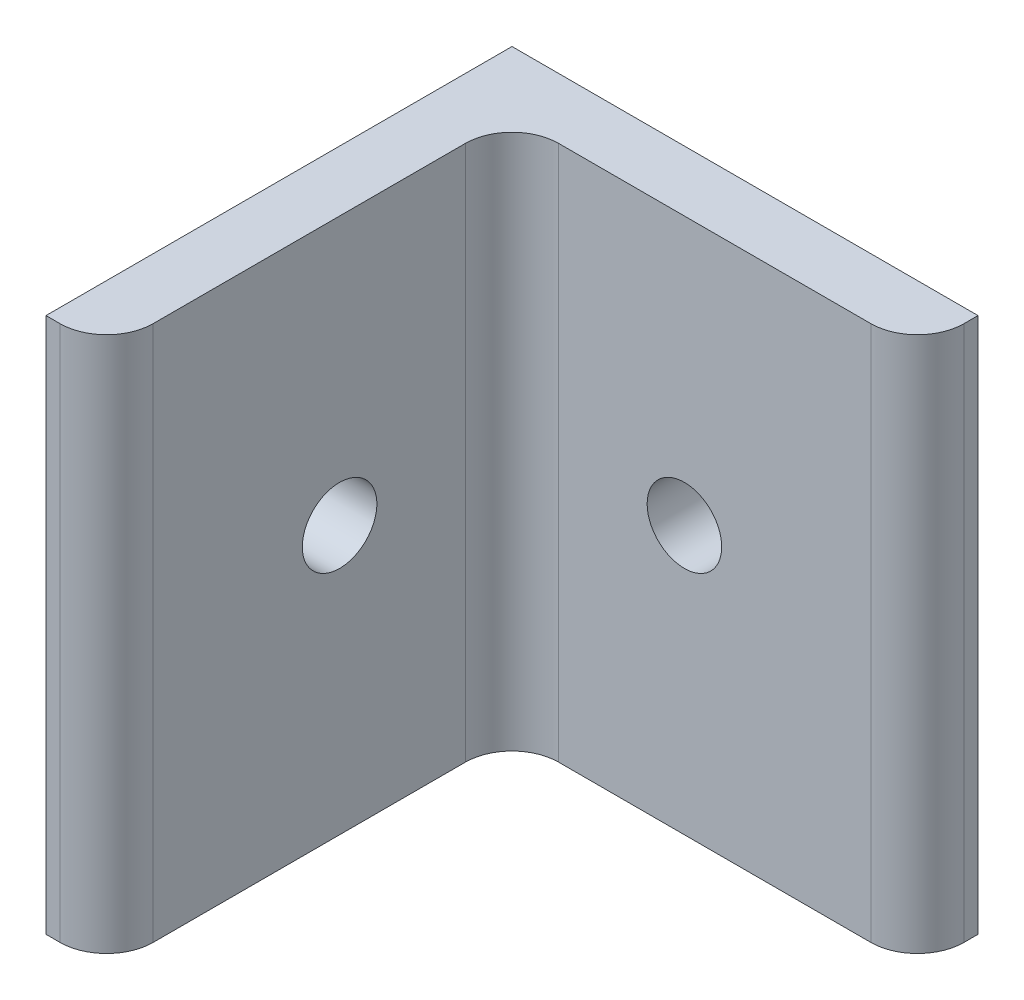
from build123d import *

# Parameters (mm, degrees)
BOSS_EXTRUDE1_DEPTH = 29.21
FILLET1_R           = 2.54
SKETCH2_R           = 2.032
CUT_EXTRUDE1_DEPTH  = 26.4
SKETCH3_R           = 2.032
CUT_EXTRUDE2_DEPTH  = 26.4


with BuildPart() as part:
    # Sketch1 → Boss-Extrude1 (new body)
    with BuildSketch(Plane(origin=(0, 0, 0), x_dir=(1, 0, 0), z_dir=(0, 1, 0))):
        Polygon((0, 0), (0, -25.4), (3.302, -25.4), (3.302, -3.302), (25.4, -3.302), (25.4, 0), align=None)
    extrude(amount=BOSS_EXTRUDE1_DEPTH)

    # Fillet1
    fillet1_edges = [part.edges().sort_by_distance(p)[0] for p in [
        (25.4, 14.605, 3.302),
        (3.302, 14.605, 3.302),
        (3.302, 14.605, 25.4),
    ]]
    fillet(fillet1_edges, radius=FILLET1_R)

    # Sketch2 → Cut-Extrude1 (cut, through all)
    with BuildSketch(Plane.ZY):
        with Locations((12.7, 14.605)):
            Circle(SKETCH2_R)
    extrude(amount=-CUT_EXTRUDE1_DEPTH, mode=Mode.SUBTRACT)

    # Sketch3 → Cut-Extrude2 (cut, through all)
    with BuildSketch(Plane(origin=(0, 0, 0), x_dir=(-1, 0, 0), z_dir=(0, 0, -1))):
        with Locations((-12.7, 14.605)):
            Circle(SKETCH3_R)
    extrude(amount=-CUT_EXTRUDE2_DEPTH, mode=Mode.SUBTRACT)


solid = part.part
